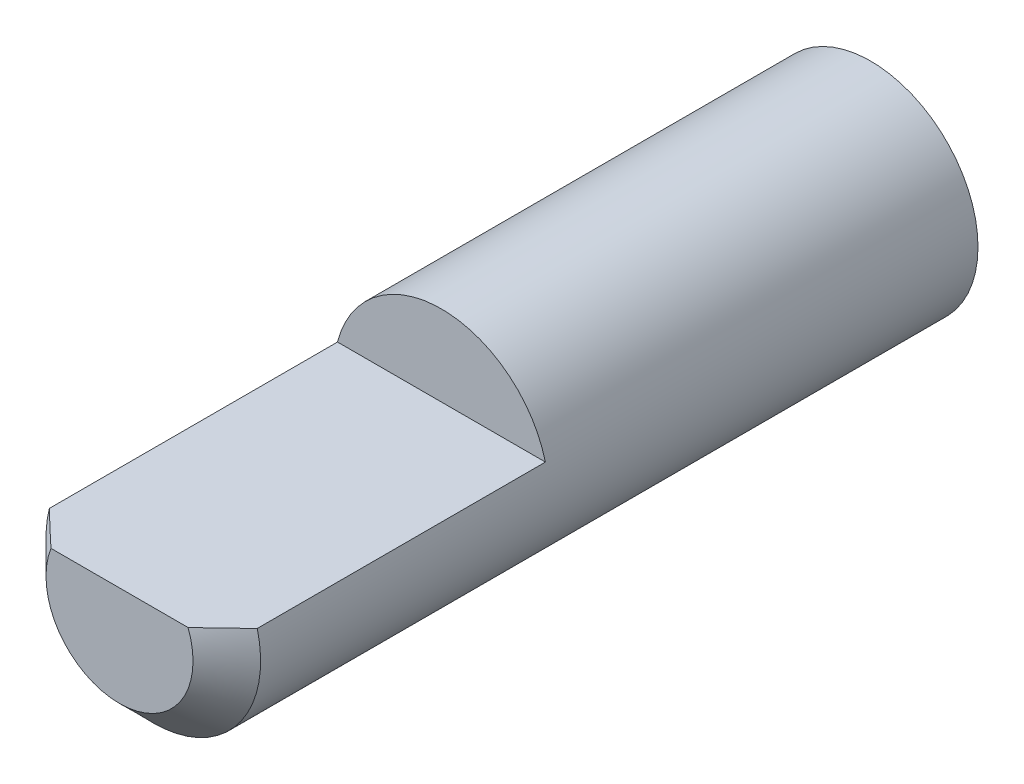
from build123d import *

# Parameters (mm, degrees)
SKETCH1_R               = 3.175
BOSS_EXTRUDE1_DEPTH     = 22.225
CUT_EXTRUDE1_DEPTH      = 1
CUT_EXTRUDE1_DEPTH_BACK = 9.525
CHAMFER1_SIZE           = 1


with BuildPart() as part:
    # Sketch1 → Boss-Extrude1 (new body)
    with BuildSketch(Plane.XY):
        Circle(SKETCH1_R)
    extrude(amount=BOSS_EXTRUDE1_DEPTH)

    # Sketch3 → Cut-Extrude1 (cut, two sides)
    with BuildSketch(Plane.XY.offset(22.225)) as cut_extrude1_sk:
        Polygon((-27.877607345, 0.7874), (-3.075813102, 0.7874), (3.075813102, 0.7874), (27.877607345, 0.7874), (27.877607345, 50.390988485), (-27.877607345, 50.390988485), align=None)
    extrude(amount=CUT_EXTRUDE1_DEPTH, mode=Mode.SUBTRACT)
    extrude(cut_extrude1_sk.sketch, amount=-CUT_EXTRUDE1_DEPTH_BACK, mode=Mode.SUBTRACT)

    # Chamfer1
    chamfer1_edges = [part.edges().sort_by_distance(p)[0] for p in [
        (-0.39681129, -3.150105681, 22.225),
    ]]
    chamfer(chamfer1_edges, length=CHAMFER1_SIZE)


solid = part.part
